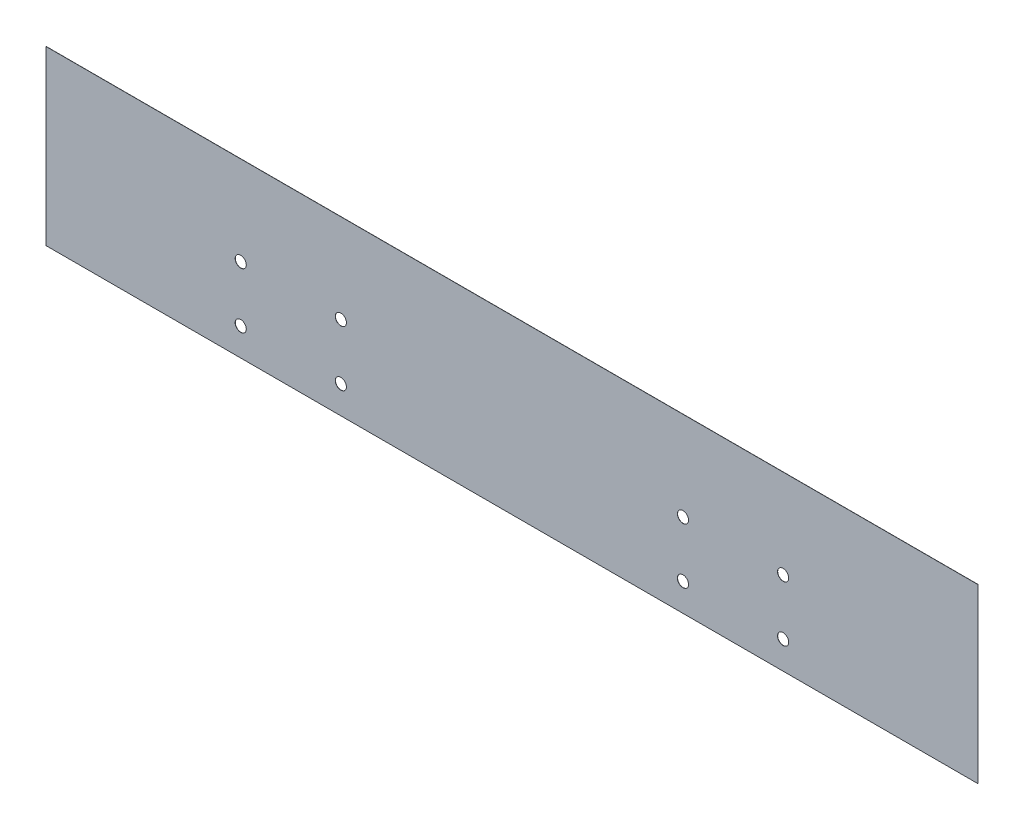
from build123d import *

# Parameters (mm, degrees)
SKETCH1_W                   = 335
SKETCH1_H                   = 62
BODY_DEPTH                  = 0.0625
SKETCH2_R                   = 2
CAMERA_MOUNTING_HOLES_DEPTH = 0.0625
SKETCH3_R                   = 2
MOUNTING_HOLES_DEPTH        = 0.0625


with BuildPart() as part:
    # Sketch1 → Body (new body)
    with BuildSketch(Plane.XY):
        Rectangle(SKETCH1_W, SKETCH1_H)
    extrude(amount=BODY_DEPTH)

    # Sketch2 → Camera Mounting holes (cut)
    with BuildSketch(Plane.XY.offset(0.0625)):
        with Locations((-61.5, -1)):
            Circle(SKETCH2_R)
        with Locations((-61.5, -21)):
            Circle(SKETCH2_R)
        with Locations((61.5, -1)):
            Circle(SKETCH2_R)
        with Locations((61.5, -21)):
            Circle(SKETCH2_R)
    extrude(amount=-CAMERA_MOUNTING_HOLES_DEPTH, mode=Mode.SUBTRACT)

    # Sketch3 → Mounting Holes (cut)
    with BuildSketch(Plane.XY.offset(0.0625)):
        with Locations((-97.5, -1)):
            Circle(SKETCH3_R)
        with Locations((-97.5, -21)):
            Circle(SKETCH3_R)
        with Locations((97.5, -1)):
            Circle(SKETCH3_R)
        with Locations((97.5, -21)):
            Circle(SKETCH3_R)
    extrude(amount=-MOUNTING_HOLES_DEPTH, mode=Mode.SUBTRACT)


solid = part.part
